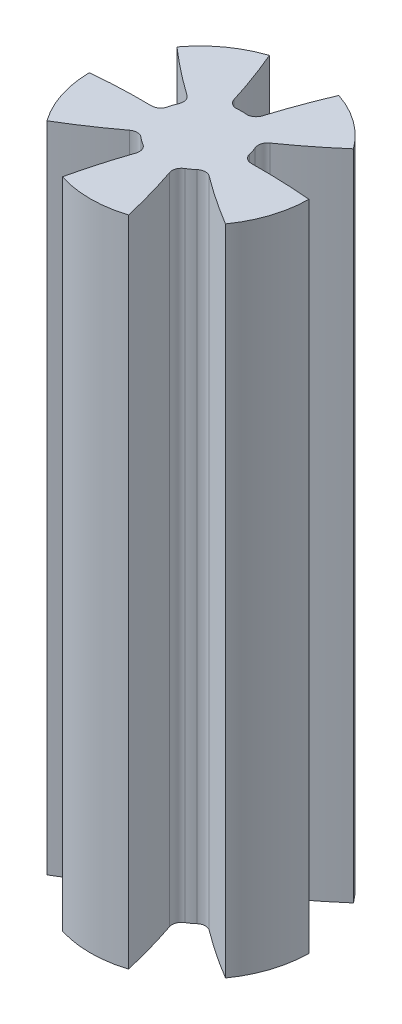
from build123d import *

# Parameters (mm, degrees)
SKETCH1_R                = 5.04
BOSS_EXTRUDE1_DEPTH      = 15
CUT_EXTRUDE1_DEPTH       = 15
FILLET2_R                = 0.43
CIRPATTERN1_COUNT        = 5
FILLET2_OF_CIRPATTERN1_R = 0.43


with BuildPart() as part:
    # Sketch1 → Boss-Extrude1 (new body, symmetric)
    with BuildSketch(Plane(origin=(0, 0, 0), x_dir=(1, 0, 0), z_dir=(0, 1, 0))):
        Circle(SKETCH1_R)
    extrude(amount=BOSS_EXTRUDE1_DEPTH, both=True)

    # Sketch2 → Cut-Extrude1 (cut, symmetric)
    with BuildSketch(Plane(origin=(0, 0, 0), x_dir=(1, 0, 0), z_dir=(0, 1, 0))):
        with BuildLine():
            ThreePointArc((-1.594286027, 4.781197764), (-1.02324782, 3.327591934), (-0.539761549, 1.842568173))
            ThreePointArc((-0.539761549, 1.842568173), (0, 1.92), (0.539761549, 1.842568173))
            ThreePointArc((0.539761549, 1.842568173), (1.02324782, 3.327591934), (1.594286027, 4.781197764))
            ThreePointArc((1.594286027, 4.781197764), (0, 5.04), (-1.594286027, 4.781197764))
        make_face()
    cut_extrude1 = extrude(amount=CUT_EXTRUDE1_DEPTH, both=True, mode=Mode.SUBTRACT)

    # Fillet2
    fillet2_edges = [part.edges().sort_by_distance(p)[0] for p in [
        (0.539761549, 0, -1.842568173),
        (-0.539761549, 0, -1.842568173),
    ]]
    fillet(fillet2_edges, radius=FILLET2_R)

    # CirPattern1: Cut-Extrude1 ×5 about axis
    cirpattern1_axis = Axis((0, 0, 0), (0, 1, 0))
    for i in range(1, CIRPATTERN1_COUNT):
        add(cut_extrude1.rotate(cirpattern1_axis, i * 360 / CIRPATTERN1_COUNT), mode=Mode.SUBTRACT)

    # Fillet2 of CirPattern1
    fillet2_of_cirpattern1_edges = [part.edges().sort_by_distance(p)[0] for p in [
        (-1.585590976, 0, -1.082728617),
        (-1.919181959, 0, -0.05604114),
        (-1.519710664, 0, 1.173405087),
        (-0.646358132, 0, 1.807932843),
        (0.646358132, 0, 1.807932843),
        (1.519710664, 0, 1.173405087),
        (1.919181959, 0, -0.05604114),
        (1.585590976, 0, -1.082728617),
    ]]
    fillet(fillet2_of_cirpattern1_edges, radius=FILLET2_OF_CIRPATTERN1_R)


solid = part.part
